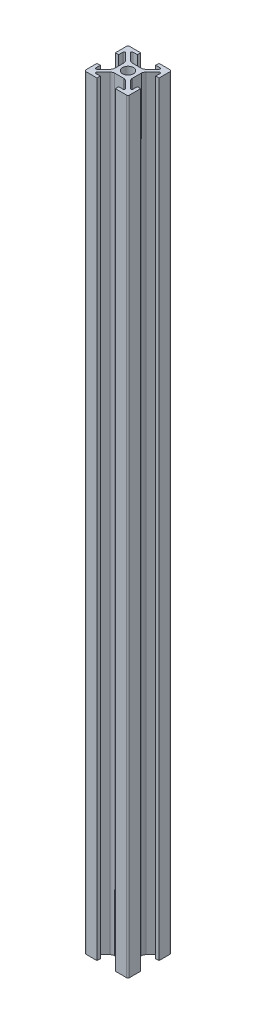
from build123d import *

# Parameters (mm, degrees)
SKETCH1_R           = 2.5
BOSS_EXTRUDE1_DEPTH = 350


with BuildPart() as part:
    # Sketch1 → Boss-Extrude1 (new body)
    with BuildSketch(Plane(origin=(0, 0, 0), x_dir=(1, 0, 0), z_dir=(0, 1, 0))):
        with BuildLine():
            Line((-3.610984523, 4.671644695), (-6.585786438, 7.646446609))
            ThreePointArc((-6.585786438, 7.646446609), (-6.694172813, 8.191341716), (-6.232233047, 8.5))
            Line((-6.232233047, 8.5), (-4.2, 8.5))
            Line((-4.2, 8.5), (-4.2, 10))
            Line((-4.2, 10), (-9.25, 10))
            ThreePointArc((-9.25, 10), (-9.780330086, 9.780330086), (-10, 9.25))
            Line((-10, 9.25), (-10, 4.2))
            Line((-10, 4.2), (-8.5, 4.2))
            Line((-8.5, 4.2), (-8.5, 6.232233047))
            ThreePointArc((-8.5, 6.232233047), (-8.191341716, 6.694172813), (-7.646446609, 6.585786438))
            Line((-7.646446609, 6.585786438), (-4.671644695, 3.610984523))
            ThreePointArc((-4.671644695, 3.610984523), (-4.244383234, 2.985253206), (-4, 2.268058063))
            Line((-4, 2.268058063), (-4, -2.268058063))
            ThreePointArc((-4, -2.268058063), (-4.244383234, -2.985253206), (-4.671644695, -3.610984523))
            Line((-4.671644695, -3.610984523), (-7.646446609, -6.585786438))
            ThreePointArc((-7.646446609, -6.585786438), (-8.191341716, -6.694172813), (-8.5, -6.232233047))
            Line((-8.5, -6.232233047), (-8.5, -4.2))
            Line((-8.5, -4.2), (-10, -4.2))
            Line((-10, -4.2), (-10, -9.25))
            ThreePointArc((-10, -9.25), (-9.780330086, -9.780330086), (-9.25, -10))
            Line((-9.25, -10), (-4.2, -10))
            Line((-4.2, -10), (-4.2, -8.5))
            Line((-4.2, -8.5), (-6.232233047, -8.5))
            ThreePointArc((-6.232233047, -8.5), (-6.694172813, -8.191341716), (-6.585786438, -7.646446609))
            Line((-6.585786438, -7.646446609), (-3.610984523, -4.671644695))
            ThreePointArc((-3.610984523, -4.671644695), (-2.985253206, -4.244383234), (-2.268058063, -4))
            Line((-2.268058063, -4), (2.268058063, -4))
            ThreePointArc((2.268058063, -4), (2.985253206, -4.244383234), (3.610984523, -4.671644695))
            Line((3.610984523, -4.671644695), (6.585786438, -7.646446609))
            ThreePointArc((6.585786438, -7.646446609), (6.694172813, -8.191341716), (6.232233047, -8.5))
            Line((6.232233047, -8.5), (4.2, -8.5))
            Line((4.2, -8.5), (4.2, -10))
            Line((4.2, -10), (9.25, -10))
            ThreePointArc((9.25, -10), (9.780330086, -9.780330086), (10, -9.25))
            Line((10, -9.25), (10, -4.2))
            Line((10, -4.2), (8.5, -4.2))
            Line((8.5, -4.2), (8.5, -6.232233047))
            ThreePointArc((8.5, -6.232233047), (8.191341716, -6.694172813), (7.646446609, -6.585786438))
            Line((7.646446609, -6.585786438), (4.671644695, -3.610984523))
            ThreePointArc((4.671644695, -3.610984523), (4.244383234, -2.985253206), (4, -2.268058063))
            Line((4, -2.268058063), (4, 2.268058063))
            ThreePointArc((4, 2.268058063), (4.244383234, 2.985253206), (4.671644695, 3.610984523))
            Line((4.671644695, 3.610984523), (7.646446609, 6.585786438))
            ThreePointArc((7.646446609, 6.585786438), (8.191341716, 6.694172813), (8.5, 6.232233047))
            Line((8.5, 6.232233047), (8.5, 4.2))
            Line((8.5, 4.2), (10, 4.2))
            Line((10, 4.2), (10, 9.25))
            ThreePointArc((10, 9.25), (9.780330086, 9.780330086), (9.25, 10))
            Line((9.25, 10), (4.2, 10))
            Line((4.2, 10), (4.2, 8.5))
            Line((4.2, 8.5), (6.232233047, 8.5))
            ThreePointArc((6.232233047, 8.5), (6.694172813, 8.191341716), (6.585786438, 7.646446609))
            Line((6.585786438, 7.646446609), (3.610984523, 4.671644695))
            ThreePointArc((3.610984523, 4.671644695), (2.985253206, 4.244383234), (2.268058063, 4))
            Line((2.268058063, 4), (-2.268058063, 4))
            ThreePointArc((-2.268058063, 4), (-2.985253206, 4.244383234), (-3.610984523, 4.671644695))
        make_face()
        Circle(SKETCH1_R, mode=Mode.SUBTRACT)
    extrude(amount=BOSS_EXTRUDE1_DEPTH)


solid = part.part
